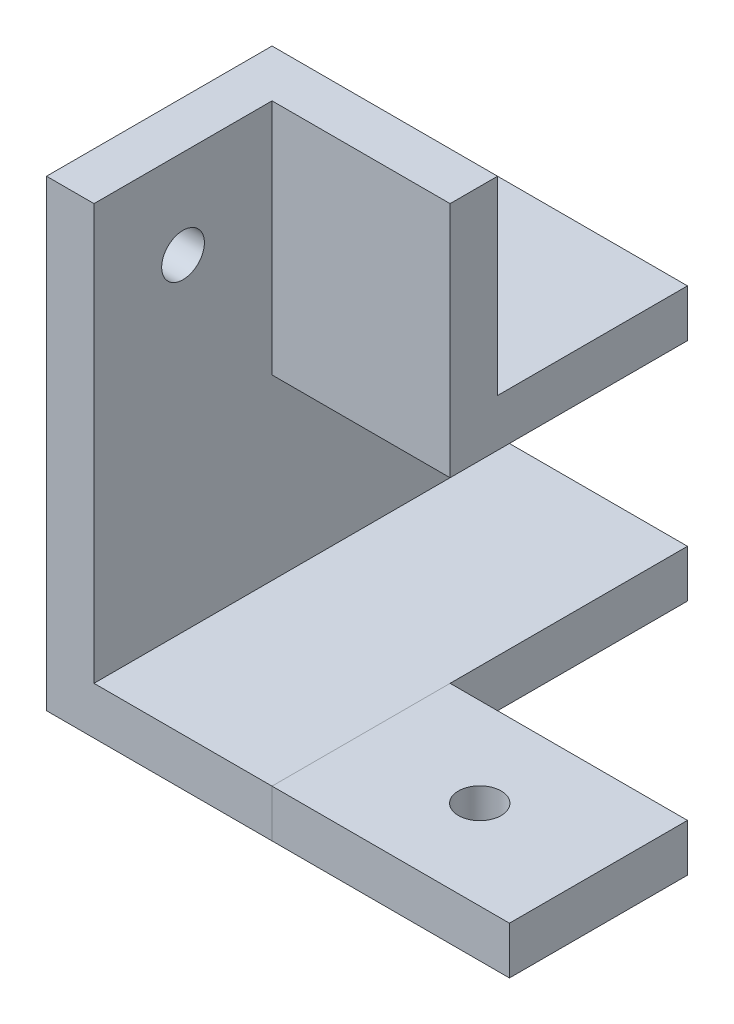
from build123d import *

# Parameters (mm, degrees)
SKETCH_1_W          = 4
SKETCH_1_H          = 19
SKETCH_1_W_2        = 15
SKETCH_1_H_2        = 4
EXTRUDE_1_DEPTH     = 15
SKETCH_2_W          = 19
SKETCH_2_H          = 19
EXTRUDE_2_DEPTH     = 4
EXTRUDE_3_DEPTH     = 20
EXTRUDE_5_DEPTH     = 20
EXTRUDE_6_DEPTH     = 20
SKETCH_7_W          = 19
SKETCH_7_H          = 4
EXTRUDE_7_DEPTH     = 16
SKETCH_8_R          = 1.8
CUT_EXTRUDE_1_DEPTH = 12
SKETCH_9_R          = 1.8
CUT_EXTRUDE_2_DEPTH = 12
SKETCH1_W           = 4
SKETCH1_H           = 15
SKETCH1_W_2         = 4.010548523
SKETCH1_H_2         = 14
CUT_EXTRUDE2_DEPTH  = 20
SKETCH2_W           = 4
SKETCH2_H           = 4
CUT_EXTRUDE3_DEPTH  = 20
CUT_EXTRUDE4_DEPTH  = 4


with BuildPart() as part:
    # 草图1 → 凸台-拉伸1 (new body)
    with BuildSketch(Plane.XY):
        with Locations((-2, 9.5)):
            Rectangle(SKETCH_1_W, SKETCH_1_H)
        with Locations((7.5, 2)):
            Rectangle(SKETCH_1_W_2, SKETCH_1_H_2)
    extrude(amount=EXTRUDE_1_DEPTH)

    # 草图2 → 凸台-拉伸2 (add)
    with BuildSketch(Plane.XY.offset(15)):
        with Locations((5.5, 9.5)):
            Rectangle(SKETCH_2_W, SKETCH_2_H)
    extrude(amount=EXTRUDE_2_DEPTH)

    # 草图3 → 凸台-拉伸3 (add)
    with BuildSketch(Plane(origin=(0, 0, 0), x_dir=(-1, 0, 0), z_dir=(0, 0, -1))):
        Polygon((-15, 19), (0, 19), (0, 4), (-15, 4), (-15, 0), (4, 0), (4, 23), (-15, 23), align=None)
    extrude(amount=EXTRUDE_3_DEPTH)



with BuildPart() as body_2:
    # 草图5 → 凸台-拉伸5 (new body)
    with BuildSketch(Plane(origin=(15, 0, 0), x_dir=(0, 0, -1), z_dir=(1, 0, 0))):
        Polygon((-19, 0), (-15, 0), (0, 0), (4, 0), (4, 18), (0, 18), (0, 4), (-15, 4), (-15, 19), (-19, 19), align=None)
    extrude(amount=EXTRUDE_5_DEPTH)

    # 草图9 → 切除-拉伸2 (cut)
    with BuildSketch(Plane.XZ):
        with Locations((25, 7.5)):
            Circle(SKETCH_9_R)
    extrude(amount=-CUT_EXTRUDE_2_DEPTH, mode=Mode.SUBTRACT)

    # Sketch1 → Cut-Extrude2 (cut)
    with BuildSketch(Plane(origin=(35, 0, 0), x_dir=(0, 0, -1), z_dir=(1, 0, 0))):
        with Locations((-17, 11.5)):
            Rectangle(SKETCH1_W, SKETCH1_H)
        with Locations((2.005274262, 11)):
            Rectangle(SKETCH1_W_2, SKETCH1_H_2)
    extrude(amount=-CUT_EXTRUDE2_DEPTH, mode=Mode.SUBTRACT)

    # Sketch2 → Cut-Extrude3 (cut)
    with BuildSketch(Plane(origin=(35, 0, 0), x_dir=(0, 0, -1), z_dir=(1, 0, 0))):
        with Locations((2, 2)):
            Rectangle(SKETCH2_W, SKETCH2_H)
    extrude(amount=-CUT_EXTRUDE3_DEPTH, mode=Mode.SUBTRACT)


with BuildPart() as body_3:
    # 草图6 → 凸台-拉伸6 (new body)
    with BuildSketch(Plane(origin=(0, 19, 0), x_dir=(1, 0, 0), z_dir=(0, 1, 0))):
        Polygon((-4, -19), (15, -19), (15, -15), (0, -15), (0, 0), (-4, 0), (-4, -16), align=None)
    extrude(amount=EXTRUDE_6_DEPTH)


with BuildPart() as part_1:
    add(part.part)

    add(body_3.part)  # 凸台-拉伸7 merges body 3
    # 草图7 → 凸台-拉伸7 (add)
    with BuildSketch(Plane(origin=(0, 23, 0), x_dir=(1, 0, 0), z_dir=(0, 1, 0))):
        with Locations((5.5, 2)):
            Rectangle(SKETCH_7_W, SKETCH_7_H)
    extrude(amount=EXTRUDE_7_DEPTH)

    # 草图8 → 切除-拉伸1 (cut)
    with BuildSketch(Plane.ZY.offset(4)):
        with Locations((7.5, 31.5)):
            Circle(SKETCH_8_R)
        with Locations((-12.5, 10.5)):
            Circle(SKETCH_8_R)
    extrude(amount=-CUT_EXTRUDE_1_DEPTH, mode=Mode.SUBTRACT)


with BuildPart() as cut_extrude4_tool:
    # Sketch3 → Cut-Extrude4 (new body)
    with BuildSketch(Plane.XY.offset(19)):
        Polygon((-4, 39), (15, 39), (15, 4), (35, 4), (35, 0), (-4, 0), align=None)
    extrude(amount=-CUT_EXTRUDE4_DEPTH)


with BuildPart() as part_2:
    add(part_1.part)

    # Cut-Extrude4: cut by cut_extrude4_tool
    add(cut_extrude4_tool.part, mode=Mode.SUBTRACT)


with BuildPart() as body_2_1:
    add(body_2.part)

    # Cut-Extrude4: cut by cut_extrude4_tool
    add(cut_extrude4_tool.part, mode=Mode.SUBTRACT)


solid = Compound([part_2.part, body_2_1.part])
